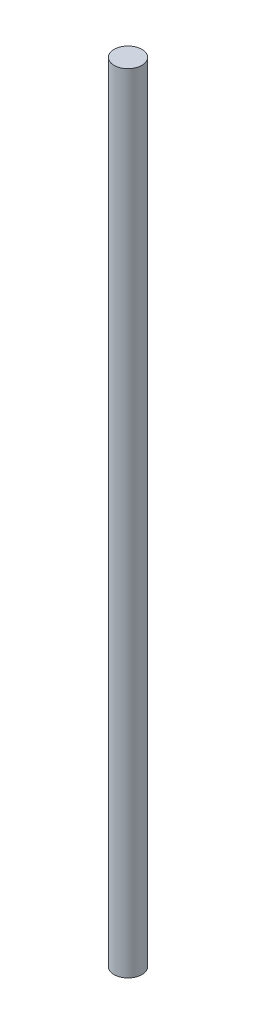
from build123d import *

# Parameters (mm, degrees)
CROQUIS1_R = 6.35


with BuildPart() as part:
    # Barrer1: sweep along a path in Croquis2
    with BuildLine(Plane.XY) as barrer1_path:
        Line((0, 0), (0, 360))
    # Croquis1 → Barrer1 (sweep)
    with BuildSketch(Plane(origin=(0, 0, 0), x_dir=(1, 0, 0), z_dir=(0, 1, 0))):
        Circle(CROQUIS1_R)
    sweep(path=barrer1_path.line)


solid = part.part
